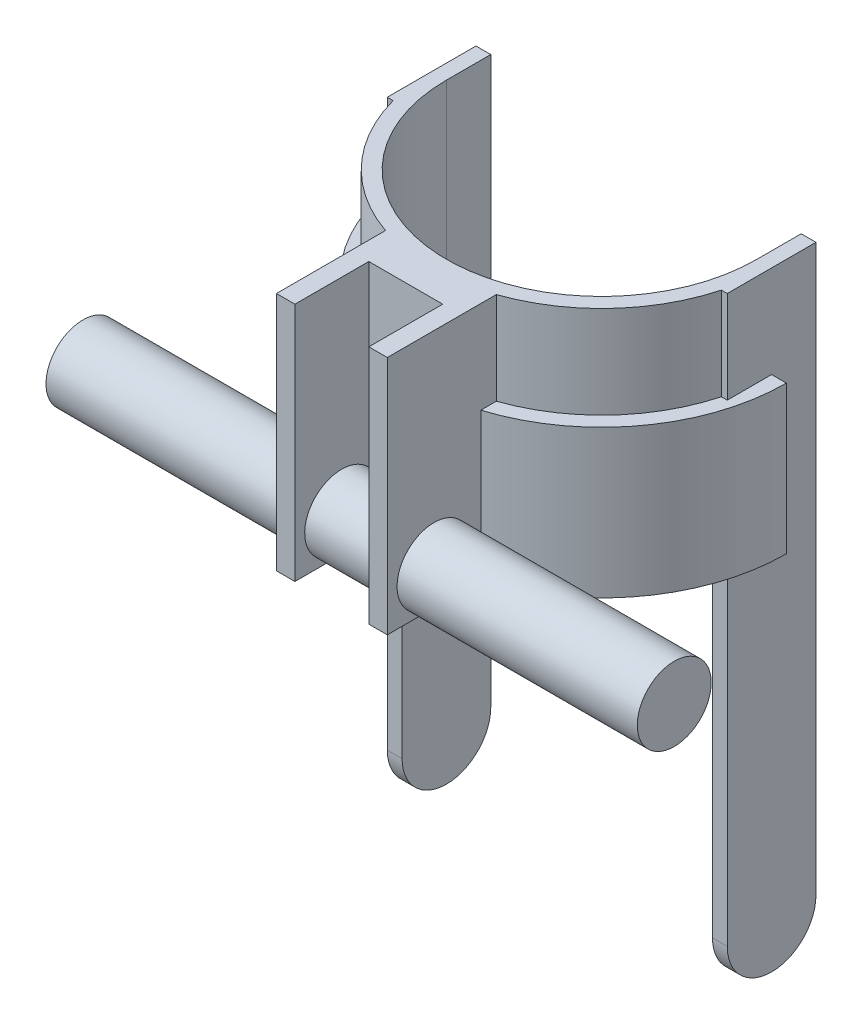
from build123d import *

# Parameters (mm, degrees)
EXTRUDE_1_DEPTH     = 50
SKETCH_2_W          = 4
SKETCH_2_H          = 24
EXTRUDE_2_DEPTH     = 210
CUT_EXTRUDE_1_DEPTH = 93
SKETCH_4_W          = 4
SKETCH_4_H          = 24
EXTRUDE_3_DEPTH     = 260
EXTRUDE_4_DEPTH     = 30
SKETCH_6_R          = 4
CUT_EXTRUDE_2_DEPTH = 97
SKETCH_8_W          = 162.90282803
SKETCH_8_H          = 303.086270548
CUT_EXTRUDE_4_DEPTH = 86
EXTRUDE_5_DEPTH     = 40
SKETCH_10_R         = 10
EXTRUDE_6_DEPTH     = 80


with BuildPart() as part:
    # 草图1 → 凸台-拉伸1 (new body, symmetric)
    with BuildSketch(Plane(origin=(0, 0, 0), x_dir=(1, 0, 0), z_dir=(0, 1, 0))):
        with BuildLine():
            Line((-46, 0), (-46, 12))
            Line((-46, 12), (-42, 12))
            Line((-42, 12), (-42, 0))
            ThreePointArc((-42, 0), (0, -42), (42, 0))
            Line((42, 0), (42, 12))
            Line((42, 12), (46, 12))
            Line((46, 12), (46, 0))
            ThreePointArc((46, 0), (37.456641601, -26.702059846), (15, -43.48562981))
            Line((15, -43.48562981), (15, -73))
            Line((15, -73), (10, -73))
            Line((10, -73), (10, -53))
            Line((10, -53), (-10, -53))
            Line((-10, -53), (-10, -73))
            Line((-10, -73), (-15, -73))
            Line((-15, -73), (-15, -43.48562981))
            ThreePointArc((-15, -43.48562981), (-37.456641601, -26.702059846), (-46, 0))
        make_face()
    extrude(amount=EXTRUDE_1_DEPTH, both=True)

    # 草图2 → 凸台-拉伸2 (add)
    with BuildSketch(Plane(origin=(0, 50, 0), x_dir=(1, 0, 0), z_dir=(0, 1, 0))):
        with Locations((-44, 0)):
            Rectangle(SKETCH_2_W, SKETCH_2_H)
        with Locations((44, 0)):
            Rectangle(SKETCH_2_W, SKETCH_2_H)
    extrude(amount=-EXTRUDE_2_DEPTH)

    # 草图3 → 切除-拉伸1 (cut, through all)
    with BuildSketch(Plane(origin=(46, 0, 0), x_dir=(0, 0, -1), z_dir=(1, 0, 0))):
        with BuildLine():
            Line((-12, -138), (-12, -169.379550042))
            Line((-12, -169.379550042), (12, -169.379550042))
            Line((12, -169.379550042), (12, -138))
            ThreePointArc((12, -138), (0, -150), (-12, -138))
        make_face()
    extrude(amount=-CUT_EXTRUDE_1_DEPTH, mode=Mode.SUBTRACT)

    # 草图4 → 凸台-拉伸3 (add)
    with BuildSketch(Plane(origin=(0, 50, 0), x_dir=(1, 0, 0), z_dir=(0, 1, 0))):
        with Locations((44, 0)):
            Rectangle(SKETCH_4_W, SKETCH_4_H)
        with Locations((-44, 0)):
            Rectangle(SKETCH_4_W, SKETCH_4_H)
    extrude(amount=EXTRUDE_3_DEPTH)

    # 草图5 → 凸台-拉伸4 (add)
    with BuildSketch(Plane(origin=(0, 310, 0), x_dir=(1, 0, 0), z_dir=(0, 1, 0))):
        with BuildLine():
            Line((-48.538644398, 12), (-42, 12))
            Line((-42, 12), (-42, 0))
            ThreePointArc((-42, 0), (0, -42), (42, 0))
            Line((42, 0), (42, 12))
            Line((42, 12), (48.538644398, 12))
            ThreePointArc((48.538644398, 12), (0, -50), (-48.538644398, 12))
        make_face()
    extrude(amount=-EXTRUDE_4_DEPTH)

    # 草图6 → 切除-拉伸2 (cut, through all)
    with BuildSketch(Plane(origin=(46, 0, 0), x_dir=(0, 0, -1), z_dir=(1, 0, 0))):
        with Locations((0, 200)):
            Circle(SKETCH_6_R)
    extrude(amount=-CUT_EXTRUDE_2_DEPTH, mode=Mode.SUBTRACT)

    # 草图8 → 切除-拉伸4 (cut, through all)
    with BuildSketch(Plane(origin=(0, 0, -12), x_dir=(-1, 0, 0), z_dir=(0, 0, -1))):
        with Locations((10.670277924, 166.543135274)):
            Rectangle(SKETCH_8_W, SKETCH_8_H)
    extrude(amount=-CUT_EXTRUDE_4_DEPTH, mode=Mode.SUBTRACT)

    # 草图9 → 凸台-拉伸5 (add)
    with BuildSketch(Plane.XZ.offset(50)):
        with BuildLine():
            Line((-50, 0), (-46, 0))
            ThreePointArc((-46, 0), (0, 46), (46, 0))
            Line((46, 0), (50, 0))
            ThreePointArc((50, 0), (0, 50), (-50, 0))
        make_face()
    extrude(amount=-EXTRUDE_5_DEPTH)

    # 草图10 → 凸台-拉伸6 (add, symmetric)
    with BuildSketch(Plane(origin=(0, 0, 0), x_dir=(0, 0, -1), z_dir=(1, 0, 0))):
        with Locations((-60.348480035, -40)):
            Circle(SKETCH_10_R)
    extrude(amount=EXTRUDE_6_DEPTH, both=True)


solid = part.part
